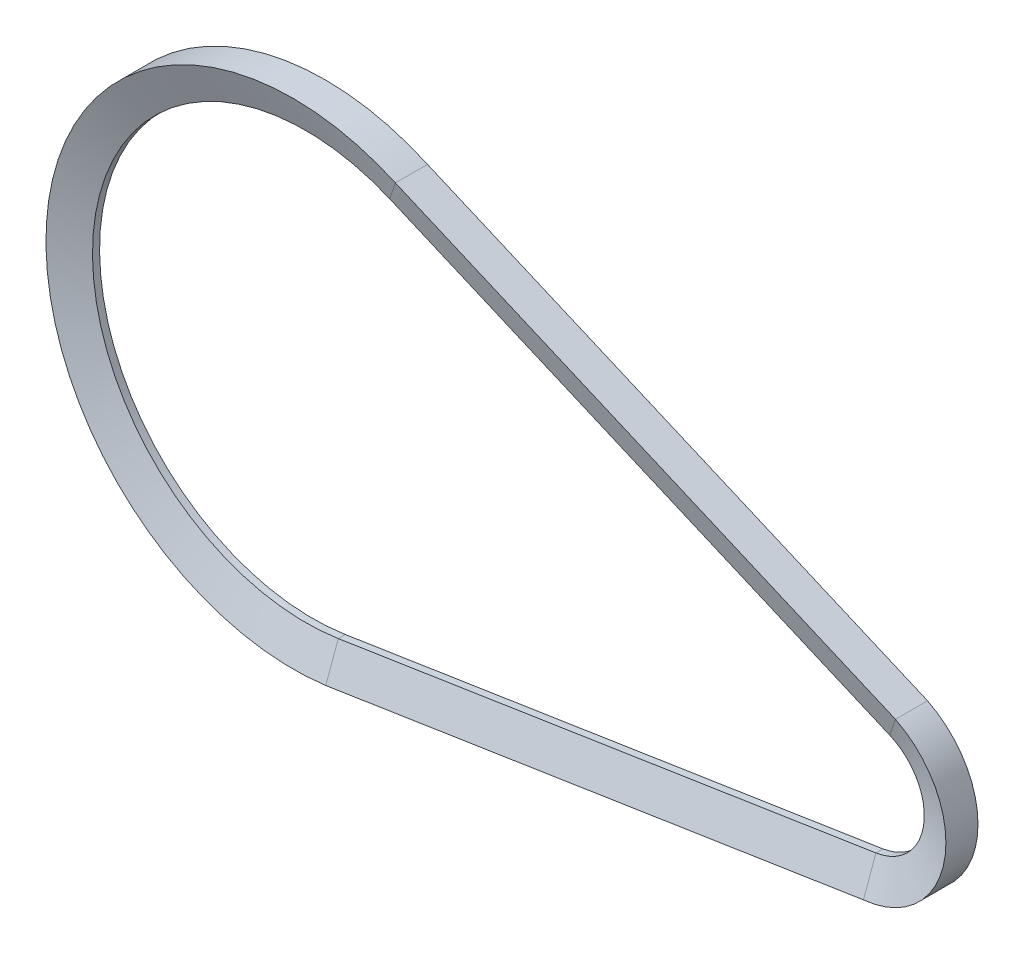
from build123d import *


with BuildPart() as part:
    # Sweep1: sweep along a path in Sketch1
    with BuildLine(Plane.XY) as sweep1_path:
        Line((18.332237974, 42.733816245), (127.408308877, -4.058365328))
        ThreePointArc((127.408308877, -4.058365328), (134.851518724, -17.062845226), (124.403812758, -27.803576593))
        Line((124.403812758, -27.803576593), (7.110625962, -45.953117396))
        ThreePointArc((7.110625962, -45.953117396), (-46.132178368, 5.837132773), (18.332237974, 42.733816245))
    # Sketch2 → Sweep1 (sweep)
    with BuildSketch(Plane(origin=(7.110625962, 0, 0), x_dir=(0, 0, -1), z_dir=(1, 0, 0))):
        Polygon((-0.770223243, -45.953117396), (0.770223243, -45.953117396), (3.5, -53.453117396), (-3.5, -53.453117396), align=None)
    sweep(path=sweep1_path.line)


solid = part.part
